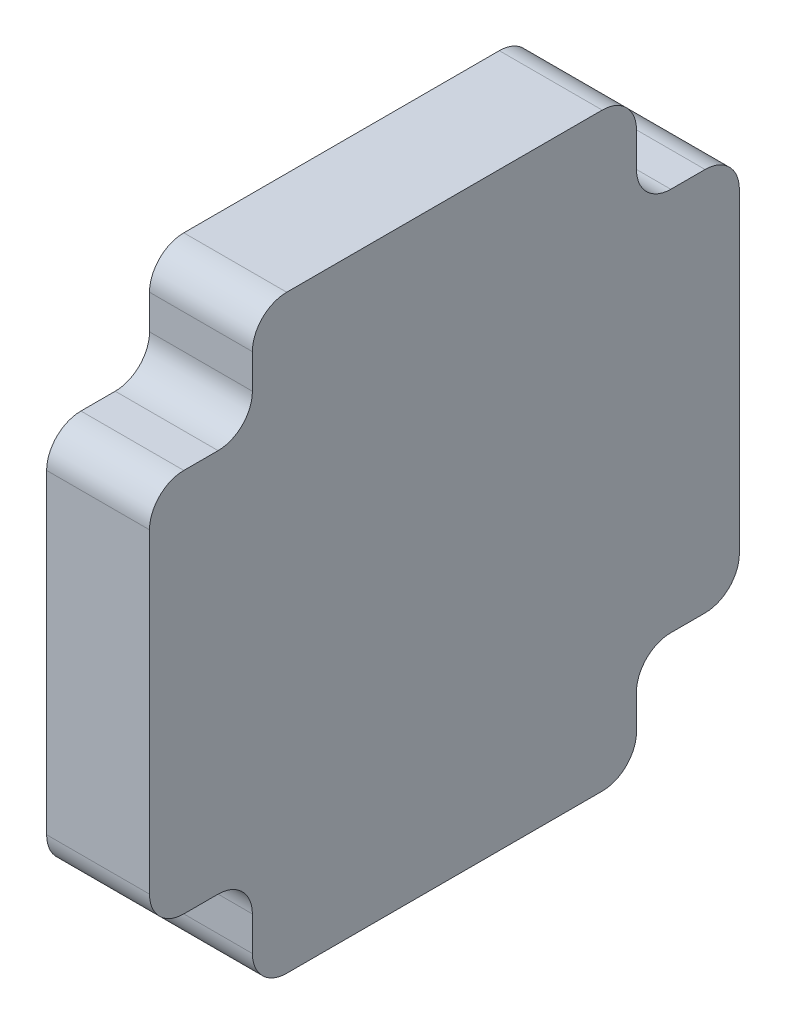
from build123d import *

# Parameters (mm, degrees)
BOSS_EXTRUDE1_DEPTH = 15


with BuildPart() as part:
    # Sketch1 → Boss-Extrude1 (new body)
    with BuildSketch(Plane(origin=(0, 0, 0), x_dir=(0, 0, -1), z_dir=(1, 0, 0))):
        with BuildLine():
            Line((20, 0), (66, 0))
            ThreePointArc((66, 0), (69.535533906, 1.464466094), (71, 5))
            Line((71, 5), (71, 10))
            ThreePointArc((71, 10), (72.464466094, 13.535533906), (76, 15))
            Line((76, 15), (81, 15))
            ThreePointArc((81, 15), (84.535533906, 16.464466094), (86, 20))
            Line((86, 20), (86, 66))
            ThreePointArc((86, 66), (84.535533906, 69.535533906), (81, 71))
            Line((81, 71), (76, 71))
            ThreePointArc((76, 71), (72.464466094, 72.464466094), (71, 76))
            Line((71, 76), (71, 81))
            ThreePointArc((71, 81), (69.535533906, 84.535533906), (66, 86))
            Line((66, 86), (20, 86))
            ThreePointArc((20, 86), (16.464466094, 84.535533906), (15, 81))
            Line((15, 81), (15, 76))
            ThreePointArc((15, 76), (13.535533906, 72.464466094), (10, 71))
            Line((10, 71), (5, 71))
            ThreePointArc((5, 71), (1.464466094, 69.535533906), (0, 66))
            Line((0, 66), (0, 20))
            ThreePointArc((0, 20), (1.464466094, 16.464466094), (5, 15))
            Line((5, 15), (10, 15))
            ThreePointArc((10, 15), (13.535533906, 13.535533906), (15, 10))
            Line((15, 10), (15, 5))
            ThreePointArc((15, 5), (16.464466094, 1.464466094), (20, 0))
        make_face()
    extrude(amount=BOSS_EXTRUDE1_DEPTH)


solid = part.part
